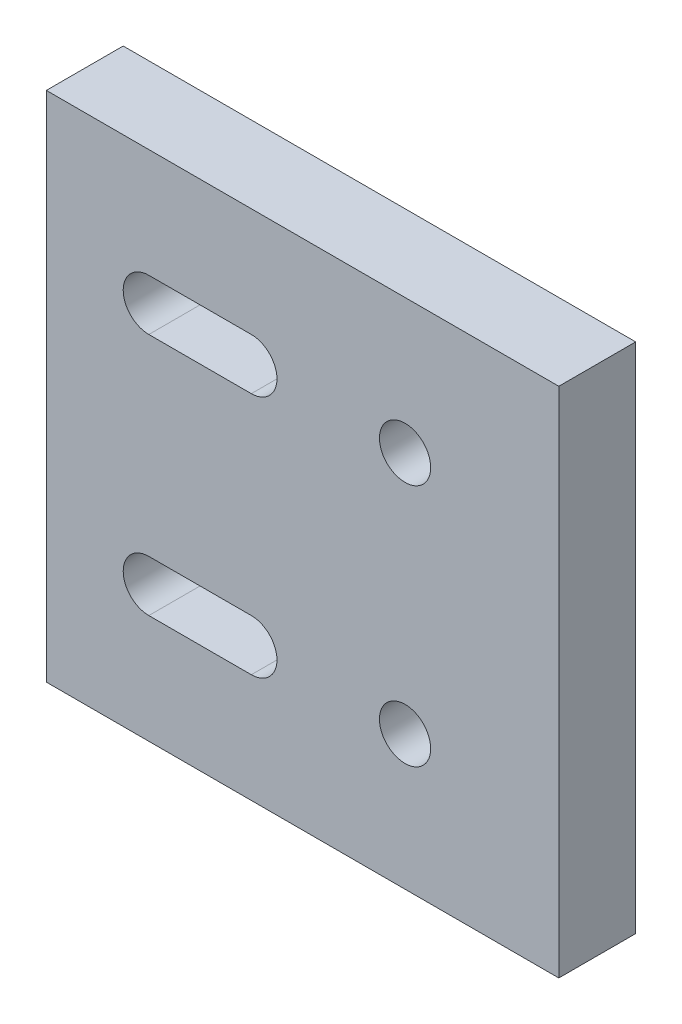
from build123d import *

# Parameters (mm, degrees)
SKETCH_1_W      = 20
SKETCH_1_H      = 20
SKETCH_1_R      = 1
EXTRUDE_1_DEPTH = 3


with BuildPart() as part:
    # 草图1 → 凸台-拉伸1 (new body)
    with BuildSketch(Plane.XY):
        Rectangle(SKETCH_1_W, SKETCH_1_H)
        with Locations((4, 4.75)):
            Circle(SKETCH_1_R, mode=Mode.SUBTRACT)
        with Locations((4, -4.75)):
            Circle(SKETCH_1_R, mode=Mode.SUBTRACT)
        with BuildLine():
            Line((-6, 5.75), (-2, 5.75))
            ThreePointArc((-2, 5.75), (-1, 4.75), (-2, 3.75))
            Line((-2, 3.75), (-6, 3.75))
            ThreePointArc((-6, 3.75), (-7, 4.75), (-6, 5.75))
        make_face(mode=Mode.SUBTRACT)
        with BuildLine():
            Line((-6, -5.75), (-2, -5.75))
            ThreePointArc((-2, -5.75), (-1, -4.75), (-2, -3.75))
            Line((-2, -3.75), (-6, -3.75))
            ThreePointArc((-6, -3.75), (-7, -4.75), (-6, -5.75))
        make_face(mode=Mode.SUBTRACT)
    extrude(amount=EXTRUDE_1_DEPTH)


solid = part.part
